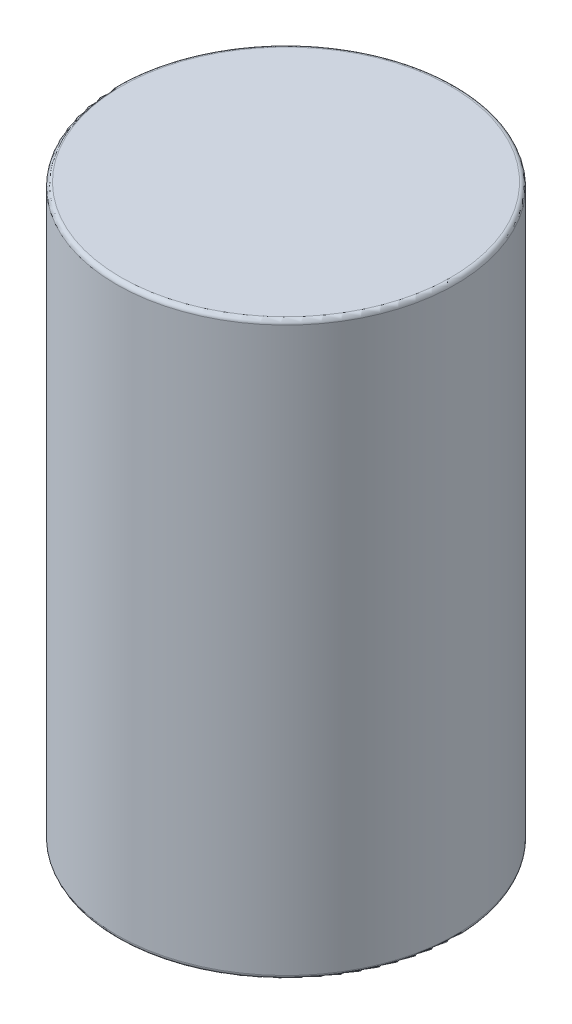
from build123d import *

# Parameters (mm, degrees)
SKETCH_1_R      = 4
EXTRUDE_1_DEPTH = 13.5
FILLET_1_R      = 0.1
FILLET_2_R      = 0.1


with BuildPart() as part:
    # Эскиз1 → Бобышка-Вытянуть1 (new body)
    with BuildSketch(Plane(origin=(0, 0, 0), x_dir=(1, 0, 0), z_dir=(0, 1, 0))):
        Circle(SKETCH_1_R)
    extrude(amount=EXTRUDE_1_DEPTH)

    # Скругление1
    fillet_1_edges = [part.edges().sort_by_distance(p)[0] for p in [
        (-4, 13.5, 0),
    ]]
    fillet(fillet_1_edges, radius=FILLET_1_R)

    # Скругление2
    fillet_2_edges = [part.edges().sort_by_distance(p)[0] for p in [
        (-4, 0, 0),
    ]]
    fillet(fillet_2_edges, radius=FILLET_2_R)


solid = part.part
